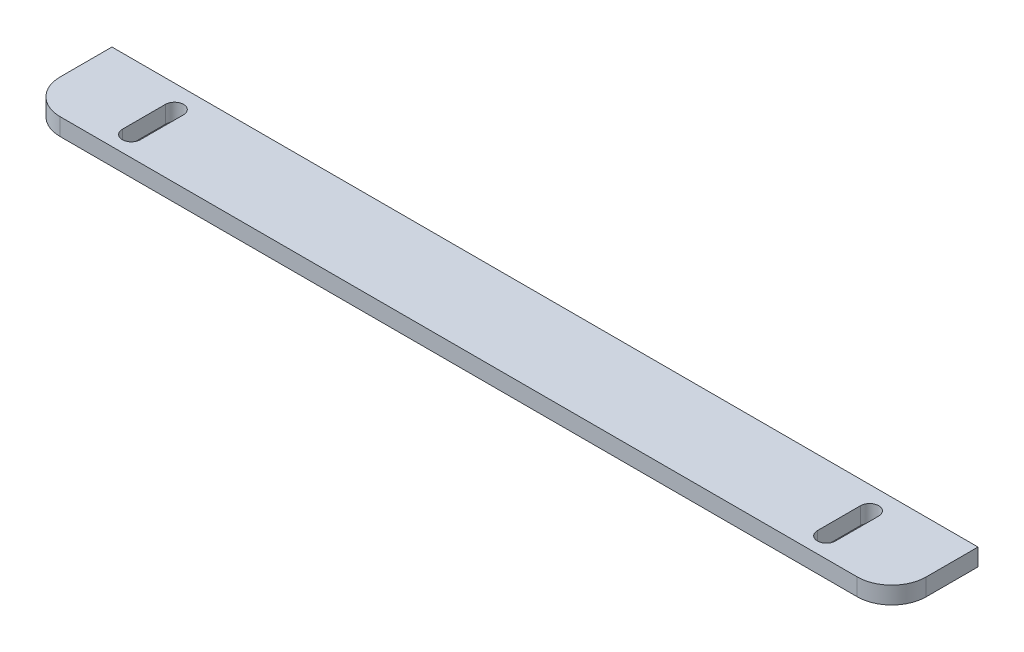
from build123d import *

# Parameters (mm, degrees)
SALIENTE_EXTRUIR1_DEPTH = 5


with BuildPart() as part:
    # Croquis1 → Saliente-Extruir1 (new body)
    with BuildSketch(Plane(origin=(0, 0, 0), x_dir=(1, 0, 0), z_dir=(0, 1, 0))):
        with BuildLine():
            Line((10, 0), (241, 0))
            ThreePointArc((241, 0), (248.071067812, 2.928932188), (251, 10))
            Line((251, 10), (251, 25))
            Line((251, 25), (0, 25))
            Line((0, 25), (0, 10))
            ThreePointArc((0, 10), (2.928932188, 2.928932188), (10, 0))
        make_face()
        with BuildLine():
            Line((27.395, 18.359540636), (27.395, 5.859540636))
            ThreePointArc((27.395, 5.859540636), (24.77, 3.234540636), (22.145, 5.859540636))
            Line((22.145, 5.859540636), (22.145, 18.359540636))
            ThreePointArc((22.145, 18.359540636), (24.77, 20.984540636), (27.395, 18.359540636))
        make_face(mode=Mode.SUBTRACT)
        with BuildLine():
            Line((223.605, 18.359540636), (223.605, 5.859540636))
            ThreePointArc((223.605, 5.859540636), (226.23, 3.234540636), (228.855, 5.859540636))
            Line((228.855, 5.859540636), (228.855, 18.359540636))
            ThreePointArc((228.855, 18.359540636), (226.23, 20.984540636), (223.605, 18.359540636))
        make_face(mode=Mode.SUBTRACT)
    extrude(amount=SALIENTE_EXTRUIR1_DEPTH)


solid = part.part
